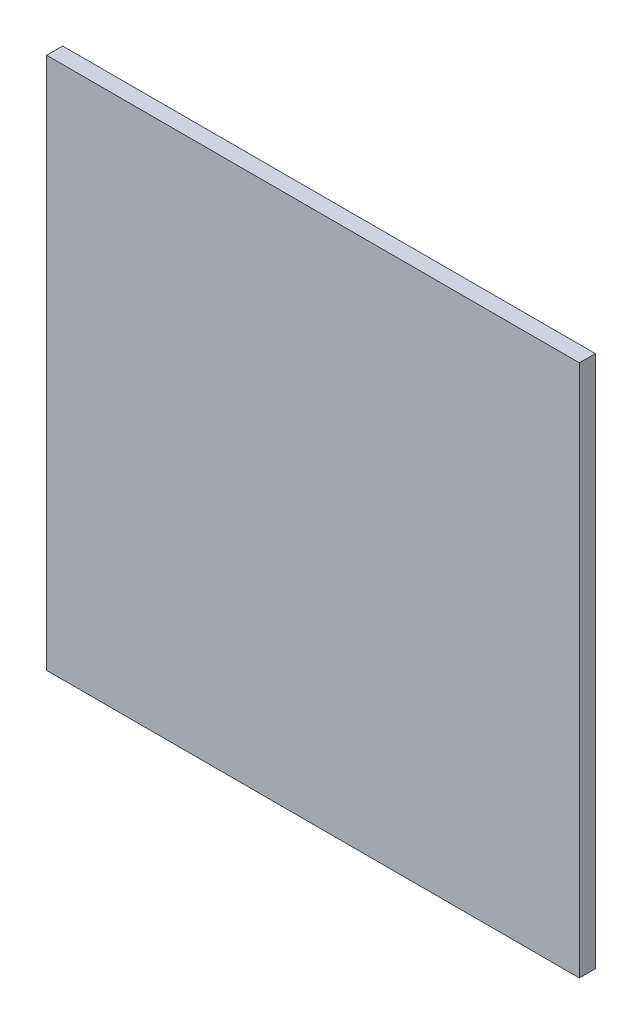
from build123d import *

# Parameters (mm, degrees)
SKETCH_1_W      = 100
SKETCH_1_H      = 100
EXTRUDE_1_DEPTH = 3


with BuildPart() as part:
    # 草图1 → 凸台-拉伸1 (new body)
    with BuildSketch(Plane.XY):
        with Locations((50, 50)):
            Rectangle(SKETCH_1_W, SKETCH_1_H)
    extrude(amount=EXTRUDE_1_DEPTH)


solid = part.part
